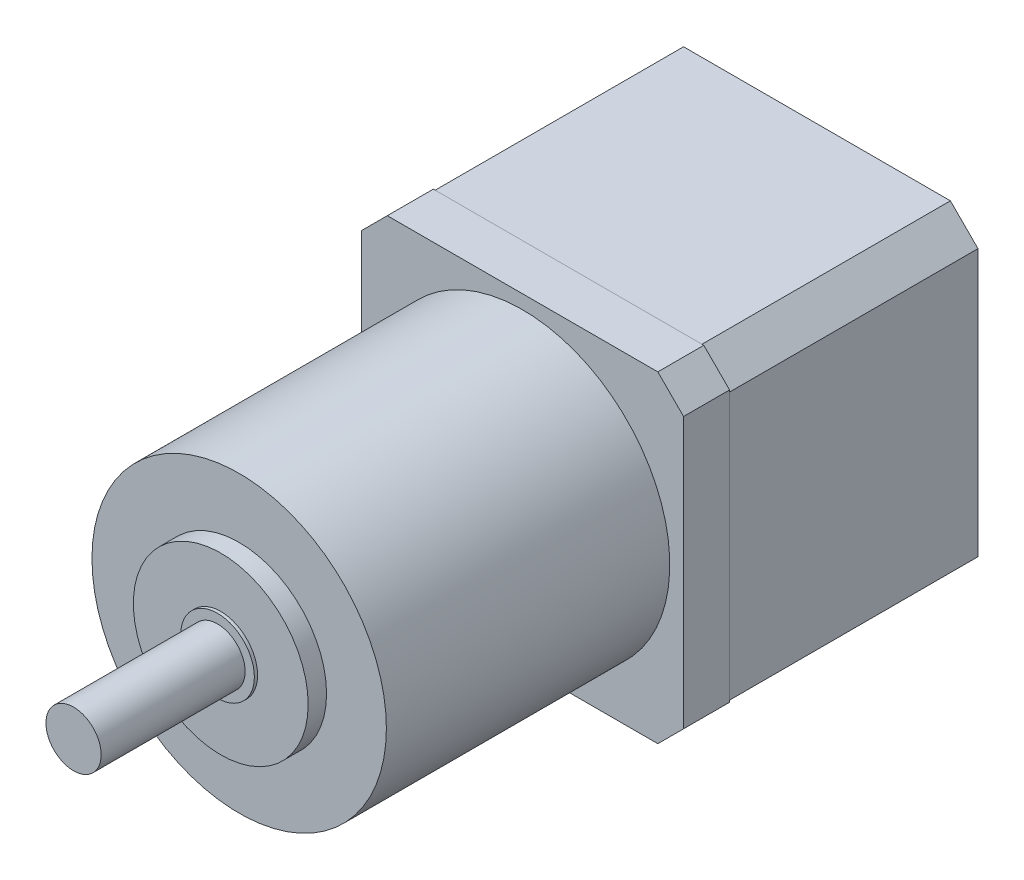
from build123d import *

# Parameters (mm, degrees)
SKETCH1_W           = 35
SKETCH1_H           = 35
BOSS_EXTRUDE1_DEPTH = 27
CHAMFER1_SIZE       = 3
SKETCH2_W           = 35
SKETCH2_H           = 35
BOSS_EXTRUDE2_DEPTH = 5
CHAMFER2_SIZE       = 2.8
SKETCH3_R           = 16
BOSS_EXTRUDE3_DEPTH = 30.8
SKETCH4_R           = 9.5
BOSS_EXTRUDE4_DEPTH = 2
SKETCH6_R           = 3
BOSS_EXTRUDE5_DEPTH = 18
SKETCH7_R           = 4
BOSS_EXTRUDE6_DEPTH = 0.35


with BuildPart() as part:
    # Sketch1 → Boss-Extrude1 (new body)
    with BuildSketch(Plane.XY):
        Rectangle(SKETCH1_W, SKETCH1_H)
    extrude(amount=BOSS_EXTRUDE1_DEPTH)

    # Chamfer1
    chamfer1_edges = [part.edges().sort_by_distance(p)[0] for p in [
        (17.5, -17.5, 13.5),
        (-17.5, -17.5, 13.5),
        (-17.5, 17.5, 13.5),
        (17.5, 17.5, 13.5),
    ]]
    chamfer(chamfer1_edges, length=CHAMFER1_SIZE)


with BuildPart() as body_2:
    # Sketch2 → Boss-Extrude2 (new body)
    with BuildSketch(Plane.XY.offset(27)):
        Rectangle(SKETCH2_W, SKETCH2_H)
    extrude(amount=BOSS_EXTRUDE2_DEPTH)

    # Chamfer2
    chamfer2_edges = [body_2.edges().sort_by_distance(p)[0] for p in [
        (17.5, -17.5, 29.5),
        (-17.5, -17.5, 29.5),
        (-17.5, 17.5, 29.5),
        (17.5, 17.5, 29.5),
    ]]
    chamfer(chamfer2_edges, length=CHAMFER2_SIZE)

    # Sketch3 → Boss-Extrude3 (add)
    with BuildSketch(Plane.XY.offset(32)):
        Circle(SKETCH3_R)
    extrude(amount=BOSS_EXTRUDE3_DEPTH)

    # Sketch4 → Boss-Extrude4 (add)
    with BuildSketch(Plane.XY.offset(62.8)):
        Circle(SKETCH4_R)
    extrude(amount=BOSS_EXTRUDE4_DEPTH)

    # Sketch6 → Boss-Extrude5 (add)
    with BuildSketch(Plane.XY.offset(62.8)):
        Circle(SKETCH6_R)
    extrude(amount=BOSS_EXTRUDE5_DEPTH)

    # Sketch7 → Boss-Extrude6 (add)
    with BuildSketch(Plane.XY.offset(64.8)):
        Circle(SKETCH7_R)
    extrude(amount=BOSS_EXTRUDE6_DEPTH)


solid = Compound([part.part, body_2.part])
